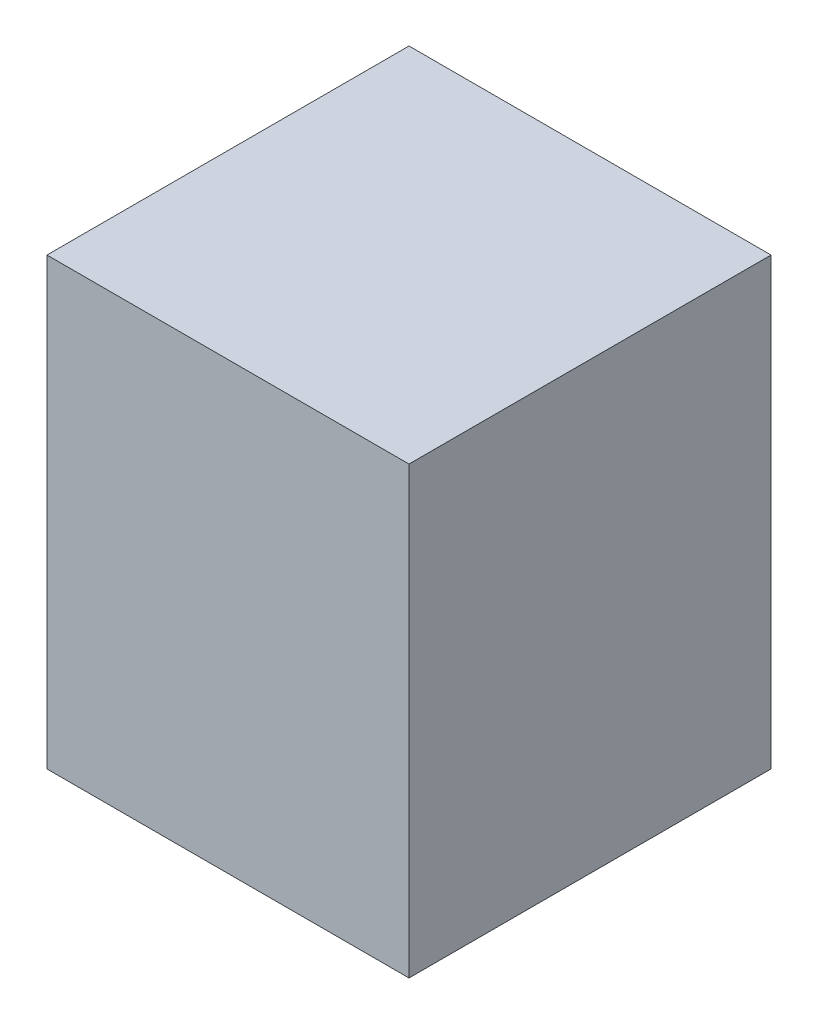
from build123d import *

# Parameters (mm, degrees)
SKETCH3_W           = 387.35
SKETCH3_H           = 387.35
BOSS_EXTRUDE1_DEPTH = 238.125


with BuildPart() as part:
    # Sketch3 → Boss-Extrude1 (new body, symmetric)
    with BuildSketch(Plane(origin=(0, 0, 0), x_dir=(1, 0, 0), z_dir=(0, 1, 0))):
        Rectangle(SKETCH3_W, SKETCH3_H)
    extrude(amount=BOSS_EXTRUDE1_DEPTH, both=True)


solid = part.part
